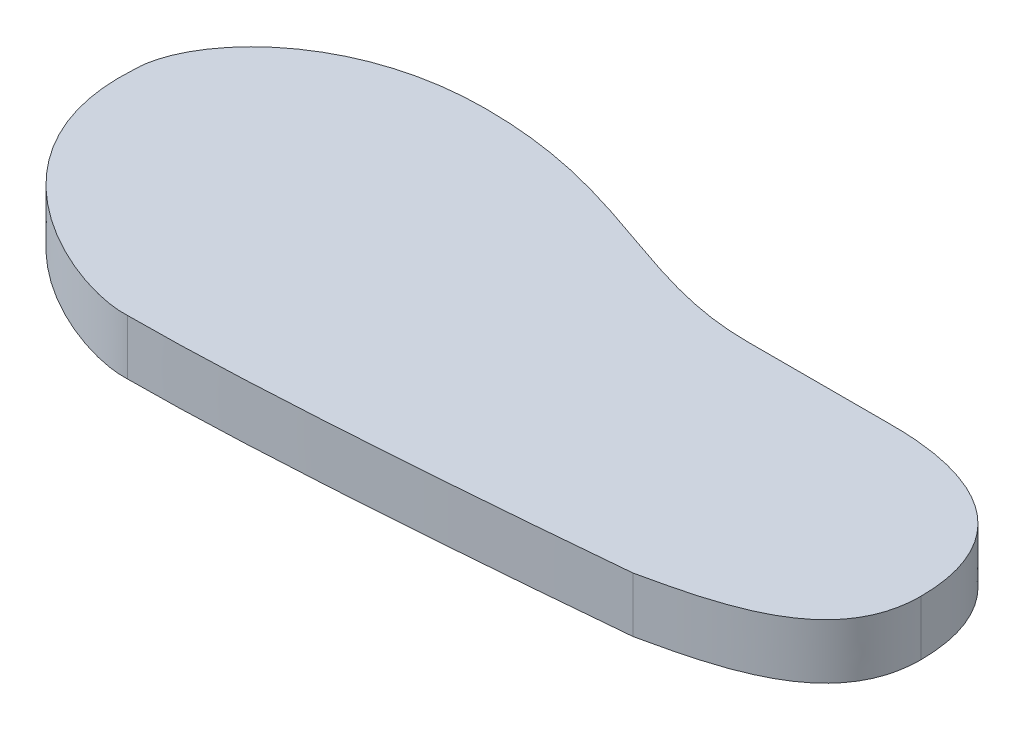
from build123d import *

# Parameters (mm, degrees)
BOSS_EXTRUDE1_DEPTH = 10


with BuildPart() as part:
    # Sketch2 → Boss-Extrude1 (new body)
    with BuildSketch(Plane(origin=(0, 0, 0), x_dir=(1, 0, 0), z_dir=(0, 1, 0))):
        with BuildLine():
            Line((-26, 24.3), (0, 24.3))
            add(Edge.make_bspline(
                [(0, 24.3), (20.683832289, 24.384713811), (29.8, 14.098961604), (29.8, 0)],
                knots=[0, 0, 0, 0, 1, 1, 1, 1], degree=3))
            add(Edge.make_bspline(
                [(29.8, 0), (29.8, -15.903385672), (12.793782652, -19.673675204), (0, -22.5)],
                knots=[0, 0, 0, 0, 1, 1, 1, 1], degree=3))
            add(Edge.make_bspline(
                [(-86.5, -27.9), (-58.742591927, -27.9), (0, -22.5)],
                knots=[0, 0, 0, 1, 1, 1], degree=2))
            add(Edge.make_bspline(
                [(-124.6, 11.6), (-126.645501882, -15.929564791), (-96.169164371, -28.458925346), (-86.5, -27.9)],
                knots=[0, 0, 0, 0, 1, 1, 1, 1], degree=3))
            add(Edge.make_bspline(
                [(-86.5, 37.2), (-111.583343569, 37.2), (-124.6, 21.145918181), (-124.6, 11.6)],
                knots=[0, 0, 0, 0, 1, 1, 1, 1], degree=3))
            add(Edge.make_bspline(
                [(-26, 24.3), (-46.37360759, 24.3), (-60.223367409, 37.2), (-86.5, 37.2)],
                knots=[0, 0, 0, 0, 1, 1, 1, 1], degree=3))
        make_face()
    extrude(amount=BOSS_EXTRUDE1_DEPTH)


solid = part.part
